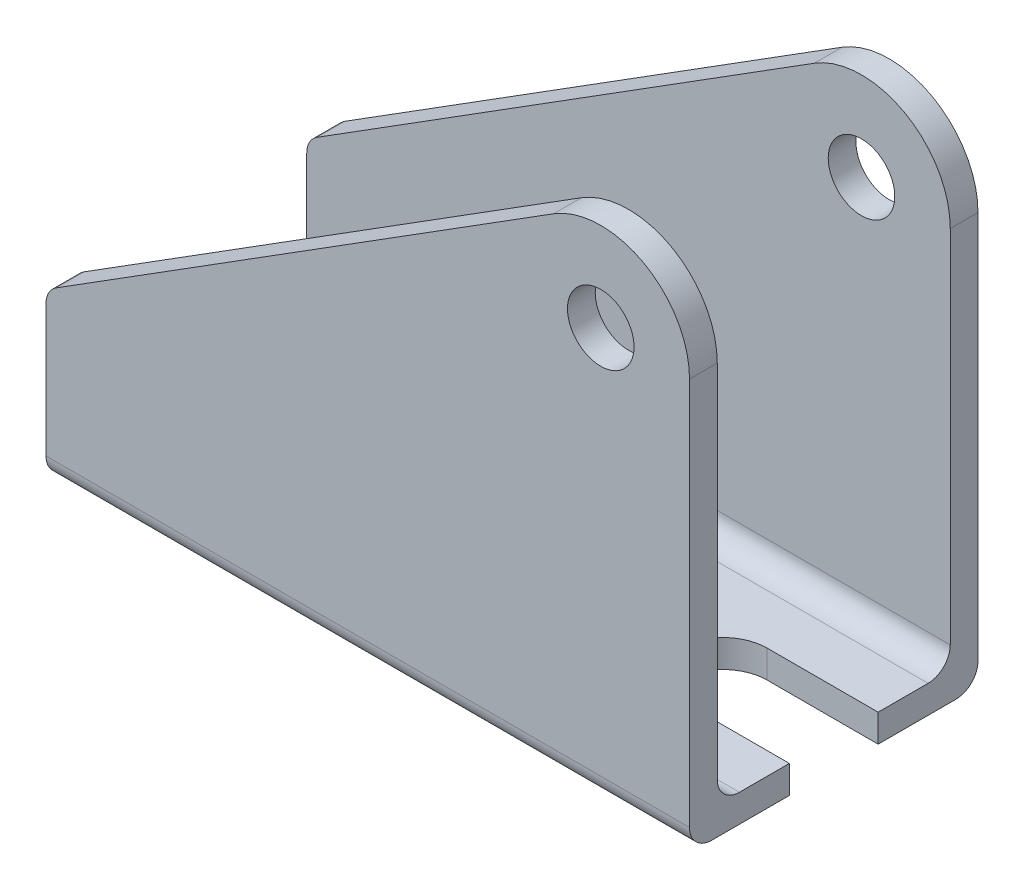
from build123d import *

# Parameters (mm, degrees)
SKETCH1_R           = 3
BOSS_EXTRUDE1_DEPTH = 26
SHELL1_T            = -2.5
FILLET1_R           = 2
SKETCH2_R           = 4
CUT_EXTRUDE1_DEPTH  = 10.780316569
CUT_EXTRUDE2_DEPTH  = 10.780316569


with BuildPart() as part:
    # Sketch1 → Boss-Extrude1 (new body)
    with BuildSketch(Plane.XY):
        with BuildLine():
            Line((-20.625157389, -9.780316569), (37.374842611, -9.780316569))
            Line((37.374842611, -9.780316569), (37.374842611, 27.219683431))
            ThreePointArc((37.374842611, 27.219683431), (33.242887907, 34.222413298), (25.115286215, 33.991402512))
            Line((25.115286215, 33.991402512), (-20.625157389, 5.219683431))
            Line((-20.625157389, 5.219683431), (-20.625157389, -9.780316569))
        make_face()
        with Locations((29.374842611, 27.219683431)):
            Circle(SKETCH1_R, mode=Mode.SUBTRACT)
    extrude(amount=BOSS_EXTRUDE1_DEPTH)

    # Shell1
    shell1_openings = [part.faces().sort_by_distance(p)[0] for p in [
        (2.245064413, 19.605542972, 13),
        (32.24397616, 32.413978135, 13),
        (37.374842611, 8.719683431, 13),
        (-20.625157389, -2.280316569, 13),
        (32.374842611, 27.219683431, 26),
    ]]
    offset(amount=SHELL1_T, openings=shell1_openings, kind=Kind.INTERSECTION)

    # Fillet1
    fillet1_edges = [part.edges().sort_by_distance(p)[0] for p in [
        (-20.625157389, 5.219683431, 1.25),
        (8.374842611, -7.280316569, 23.5),
        (8.374842611, -7.280316569, 2.5),
        (8.374842611, -9.780316569, 0),
        (8.374842611, -9.780316569, 26),
        (-20.625157389, 5.219683431, 24.75),
    ]]
    fillet(fillet1_edges, radius=FILLET1_R)

    # Sketch2 → Cut-Extrude1 (cut, through all)
    with BuildSketch(Plane(origin=(0, 0, 0), x_dir=(1, 0, 0), z_dir=(0, 1, 0))):
        with Locations((-8.625157389, -13)):
            Circle(SKETCH2_R)
    extrude(amount=-CUT_EXTRUDE1_DEPTH, mode=Mode.SUBTRACT)

    # Sketch3 → Cut-Extrude2 (cut, through all)
    with BuildSketch(Plane(origin=(0, 0, 0), x_dir=(1, 0, 0), z_dir=(0, 1, 0))):
        with BuildLine():
            Line((37.374842611, -9), (27.374842611, -9))
            ThreePointArc((27.374842611, -9), (23.374842611, -13), (27.374842611, -17))
            Line((27.374842611, -17), (37.374842611, -17))
            Line((37.374842611, -17), (37.374842611, -9))
        make_face()
    extrude(amount=-CUT_EXTRUDE2_DEPTH, mode=Mode.SUBTRACT)


solid = part.part
